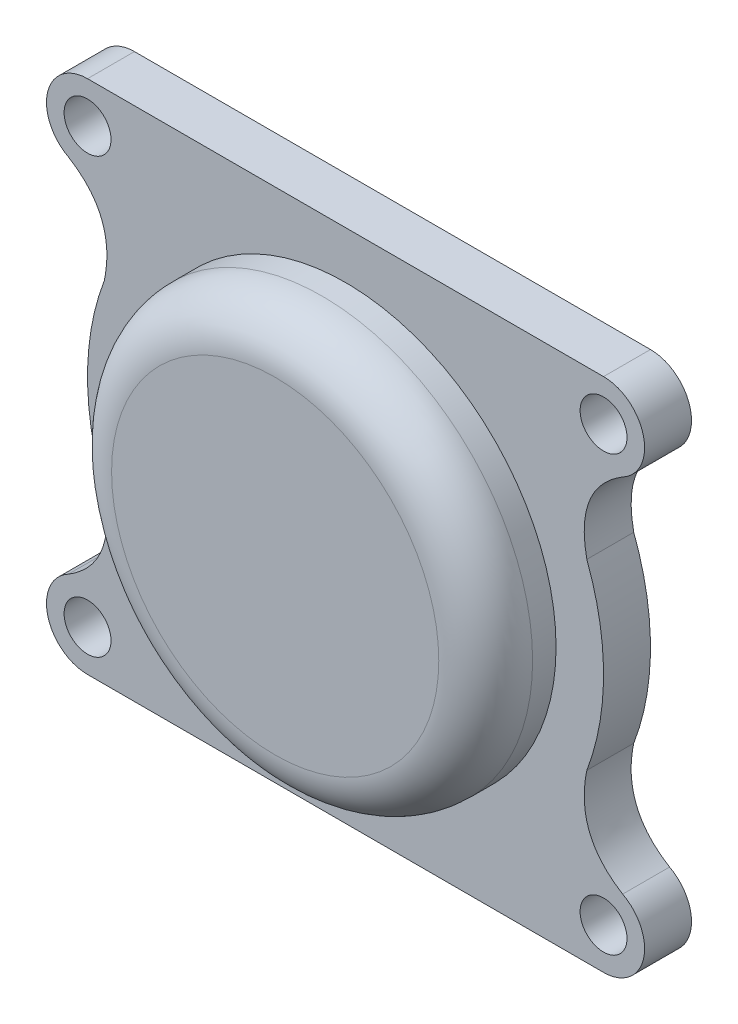
from build123d import *

# Parameters (mm, degrees)
SKETCH1_R           = 1
SKETCH1_R_2         = 7.975
BOSS_EXTRUDE1_DEPTH = 2
SKETCH2_R           = 8.975
SKETCH2_R_2         = 7.975
BOSS_EXTRUDE2_DEPTH = 2
SKETCH3_R           = 8.975
BOSS_EXTRUDE3_DEPTH = 1
FILLET1_R           = 2


with BuildPart() as part:
    # Sketch1 → Boss-Extrude1 (new body)
    with BuildSketch(Plane.XY):
        with BuildLine():
            Line((-10.866636256, -11.400091233), (11.133363744, -11.400091233))
            ThreePointArc((11.133363744, -11.400091233), (12.832206534, -10.070130727), (11.948884962, -8.101729149))
            add(Edge.make_bspline(
                [(11.948884962, -8.101729149), (9.883447826, -6.844292891), (10.420778008, -4.294845111)],
                knots=[0, 0, 0, 1, 1, 1], degree=2))
            ThreePointArc((10.420778008, -4.294845111), (11.133363745, -0.400091249), (10.420778018, 3.494662613))
            add(Edge.make_bspline(
                [(10.420778018, 3.494662613), (9.883447814, 6.044110418), (11.948884963, 7.301546684)],
                knots=[0, 0, 0, 1, 1, 1], degree=2))
            ThreePointArc((11.948884963, 7.301546684), (12.832206534, 9.269948262), (11.133363744, 10.599908767))
            Line((11.133363744, 10.599908767), (-10.866636256, 10.599908767))
            ThreePointArc((-10.866636256, 10.599908767), (-12.565479045, 9.269948261), (-11.682157474, 7.301546683))
            add(Edge.make_bspline(
                [(-11.682157474, 7.301546683), (-9.616720338, 6.044110425), (-10.15405052, 3.494662645)],
                knots=[0, 0, 0, 1, 1, 1], degree=2))
            ThreePointArc((-10.15405052, 3.494662645), (-10.866636257, -0.400091216), (-10.15405053, -4.294845078))
            add(Edge.make_bspline(
                [(-10.15405053, -4.294845078), (-9.616720326, -6.844292883), (-11.682157475, -8.101729149)],
                knots=[0, 0, 0, 1, 1, 1], degree=2))
            ThreePointArc((-11.682157475, -8.101729149), (-12.565479045, -10.070130727), (-10.866636256, -11.400091233))
        make_face()
        with Locations((-10.866636256, -9.650091233)):
            Circle(SKETCH1_R, mode=Mode.SUBTRACT)
        with Locations((11.133363744, -9.650091233)):
            Circle(SKETCH1_R, mode=Mode.SUBTRACT)
        with Locations((-10.866636256, 8.849908767)):
            Circle(SKETCH1_R, mode=Mode.SUBTRACT)
        with Locations((11.133363744, 8.849908767)):
            Circle(SKETCH1_R, mode=Mode.SUBTRACT)
        with Locations((0.133363744, -0.400091233)):
            Circle(SKETCH1_R_2, mode=Mode.SUBTRACT)
    extrude(amount=BOSS_EXTRUDE1_DEPTH)

    # Sketch2 → Boss-Extrude2 (add)
    with BuildSketch(Plane.XY.offset(2)):
        with Locations((0.133363744, -0.400091233)):
            Circle(SKETCH2_R)
        with Locations((0.133363744, -0.400091233)):
            Circle(SKETCH2_R_2, mode=Mode.SUBTRACT)
    extrude(amount=BOSS_EXTRUDE2_DEPTH)

    # Sketch3 → Boss-Extrude3 (add)
    with BuildSketch(Plane.XY.offset(4)):
        with Locations((0.133363744, -0.400091233)):
            Circle(SKETCH3_R)
    extrude(amount=BOSS_EXTRUDE3_DEPTH)

    # Fillet1
    fillet1_edges = [part.edges().sort_by_distance(p)[0] for p in [
        (-8.841636256, -0.400091233, 5),
        (-7.841636256, -0.400091233, 4),
    ]]
    fillet(fillet1_edges, radius=FILLET1_R)


solid = part.part
